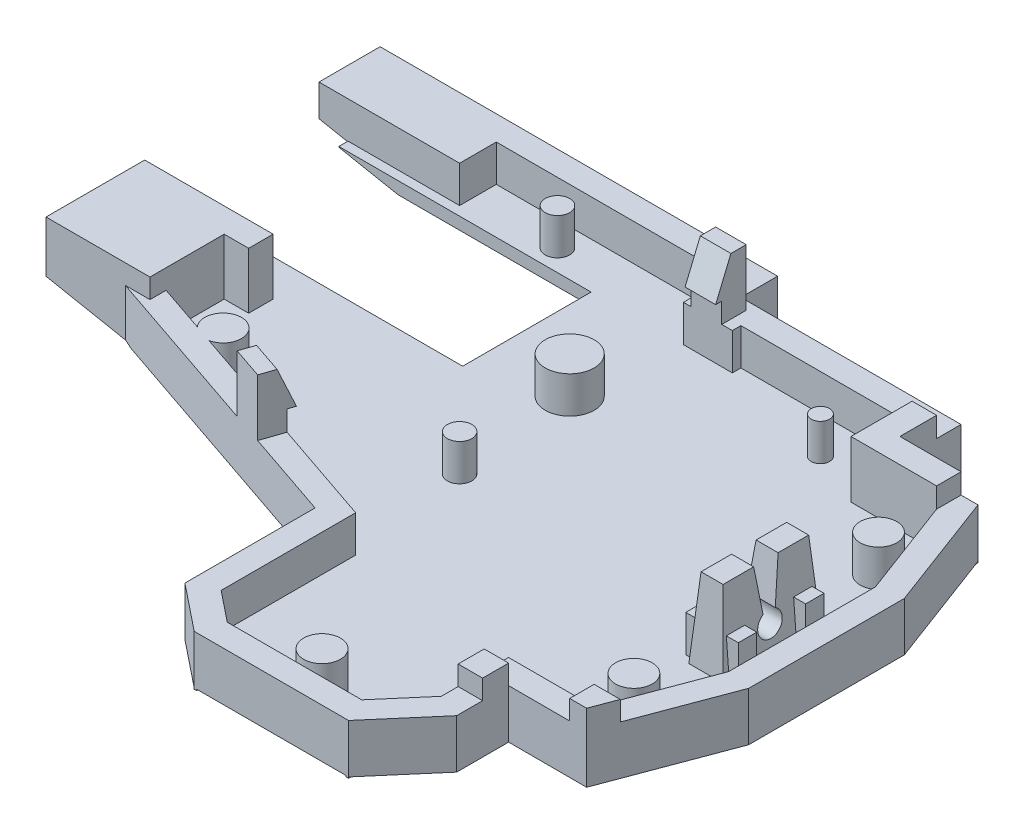
from build123d import *

# Parameters (mm, degrees)
SKETCH13_W           = 50
SKETCH13_H           = 45
BOSS_EXTRUDE4_DEPTH  = 1.6
SKETCH14_W           = 10
SKETCH14_H           = 8
CUT_EXTRUDE6_DEPTH   = 2.6
SKETCH15_W           = 18
SKETCH15_H           = 3
CUT_EXTRUDE7_DEPTH   = 2.6
SKETCH16_W           = 4
SKETCH16_H           = 0.7
CUT_EXTRUDE8_DEPTH   = 2.6
CUT_EXTRUDE9_DEPTH   = 2.6
SKETCH18_W           = 21.109590793
SKETCH18_H           = 22.840524871
CUT_EXTRUDE10_DEPTH  = 2.6
CUT_EXTRUDE11_DEPTH  = 2.6
SKETCH22_W           = 2
SKETCH22_H           = 3
CUT_EXTRUDE12_DEPTH  = 2.6
CUT_EXTRUDE13_DEPTH  = 2.6
CUT_EXTRUDE14_DEPTH  = 2.6
SKETCH25_W           = 2.8
SKETCH25_H           = 8
CUT_EXTRUDE15_DEPTH  = 2.6
BOSS_EXTRUDE6_DEPTH  = 6
SKETCH30_W           = 2.8
SKETCH30_H           = 8
BOSS_EXTRUDE7_DEPTH  = 3.5
CUT_EXTRUDE16_DEPTH  = 4.6
SKETCH32_W           = 2.8
SKETCH32_H           = 8
BOSS_EXTRUDE8_DEPTH  = 4.6
CUT_EXTRUDE18_DEPTH  = 4.6
SKETCH37_R           = 1
CUT_EXTRUDE19_DEPTH  = 4.6
CUT_EXTRUDE20_DEPTH  = 4.6
CUT_EXTRUDE21_START  = 6
CUT_EXTRUDE21_DEPTH  = 20.059798
BOSS_EXTRUDE9_DEPTH  = 4.6
SKETCH44_W           = 4.3
SKETCH44_H           = 1.5
BOSS_EXTRUDE11_DEPTH = 3
SKETCH45_R           = 1.5
SKETCH45_R_2         = 1
SKETCH45_R_3         = 1.999622229
SKETCH45_R_4         = 1.503341979
SKETCH45_R_5         = 0.75
BOSS_EXTRUDE12_DEPTH = 3
SKETCH46_W           = 2.5
SKETCH46_H           = 2
SKETCH46_W_2         = 2
BOSS_EXTRUDE13_DEPTH = 1.65
SKETCH47_W           = 3
SKETCH47_H           = 3
BOSS_EXTRUDE14_DEPTH = 3
SKETCH48_W           = 2
SKETCH48_H           = 16.336241737
CUT_EXTRUDE22_DEPTH  = 3
SKETCH49_W           = 21.336241737
SKETCH49_H           = 3
BOSS_EXTRUDE15_DEPTH = 13
SKETCH50_W           = 67
SKETCH50_H           = 49
BOSS_EXTRUDE16_DEPTH = 3
SKETCH51_W           = 5
SKETCH51_H           = 11
BOSS_EXTRUDE17_DEPTH = 15.6
CUT_EXTRUDE23_DEPTH  = 1.65
SKETCH53_W           = 2
SKETCH53_H           = 2.129349353
BOSS_EXTRUDE18_DEPTH = 1.6
SKETCH55_W           = 2.5
SKETCH55_H           = 2.5
BOSS_EXTRUDE20_DEPTH = 3
CUT_EXTRUDE24_DEPTH  = 3
SKETCH58_W           = 20
SKETCH58_H           = 10.5
SKETCH58_W_2         = 2
SKETCH58_H_2         = 2
CUT_EXTRUDE29_DEPTH  = 1
BOSS_EXTRUDE21_DEPTH = 3
BOSS_EXTRUDE22_REACH = 41.731
SKETCH61_W           = 2.5
SKETCH61_H           = 1.65
CUT_EXTRUDE30_DEPTH  = 3
CUT_EXTRUDE31_REACH  = 43.731
SKETCH64_W           = 2.551500858
SKETCH64_H           = 4.310788114
CUT_EXTRUDE32_DEPTH  = 4.65
SKETCH65_W           = 2
SKETCH65_H           = 2
BOSS_EXTRUDE23_DEPTH = 4
SKETCH66_W           = 2
SKETCH66_H           = 2
BOSS_EXTRUDE24_DEPTH = 1.6
SKETCH67_W           = 2.5
SKETCH67_H           = 2
BOSS_EXTRUDE25_DEPTH = 3
CUT_EXTRUDE33_DEPTH  = 3
BOSS_EXTRUDE26_DEPTH = 1.65
SKETCH70_W           = 5.055009343
SKETCH70_H           = 5.560438358
CUT_EXTRUDE34_DEPTH  = 3
BOSS_EXTRUDE27_DEPTH = 3
CUT_EXTRUDE35_DEPTH  = 3
BOSS_EXTRUDE28_REACH = 39.863
CUT_EXTRUDE36_DEPTH  = 3
FILLET8_R            = 1
SKETCH76_W           = 7
SKETCH76_H           = 14.5
BOSS_EXTRUDE29_DEPTH = 14.5
BOSS_EXTRUDE30_DEPTH = 2
CUT_EXTRUDE37_DEPTH  = 2
BOSS_EXTRUDE31_DEPTH = 2.684479
SKETCH85_W           = 30.566158209
SKETCH85_H           = 1.725230041
BOSS_EXTRUDE33_DEPTH = 3
BOSS_EXTRUDE34_DEPTH = 3
BOSS_EXTRUDE35_DEPTH = 3
SKETCH88_W           = 27.09375
SKETCH88_H           = 14.5
BOSS_EXTRUDE36_DEPTH = 1.6
SKETCH90_W           = 7
SKETCH90_H           = 14.5
BOSS_EXTRUDE37_DEPTH = 1.6
SKETCH93_W           = 5
SKETCH93_H           = 11
BOSS_EXTRUDE38_DEPTH = 0.5
SKETCH94_W           = 8.605758832
SKETCH94_H           = 2
BOSS_EXTRUDE39_DEPTH = 15.6
SKETCH96_W           = 8.605758832
SKETCH96_H           = 2
BOSS_EXTRUDE40_DEPTH = 0.5
SKETCH97_W           = 2
SKETCH97_H           = 49
BOSS_EXTRUDE41_DEPTH = 19.1
SKETCH98_W           = 69
SKETCH98_H           = 2
BOSS_EXTRUDE42_DEPTH = 19.1
SKETCH99_W           = 2
SKETCH99_H           = 3
BOSS_EXTRUDE43_DEPTH = 2.087376
SKETCH100_W          = 2
SKETCH100_H          = 51
BOSS_EXTRUDE45_DEPTH = 19.1
SKETCH101_W          = 71
SKETCH101_H          = 2
BOSS_EXTRUDE46_DEPTH = 19.1
BOSS_EXTRUDE47_DEPTH = 16.1
BOSS_EXTRUDE48_DEPTH = 16.1
FILLET9_R            = 2
SKETCH105_OUTSIDE_W  = 91.128
SKETCH105_OUTSIDE_H  = 73.128
CUT_EXTRUDE38_DEPTH  = 3
SKETCH106_W          = 77.0560479
SKETCH106_H          = 58.523580684
CUT_EXTRUDE39_DEPTH  = 20.1
SKETCH107_W          = 13.37564089
SKETCH107_H          = 6.179627402
CUT_EXTRUDE40_DEPTH  = 11.5
CUT_EXTRUDE41_DEPTH  = 4
SKETCH114_W          = 66.336817547
SKETCH114_H          = 51.668552302
CUT_EXTRUDE42_DEPTH  = 2
BOSS_EXTRUDE49_DEPTH = 6.5
SKETCH116_W          = 0.628599621
SKETCH116_H          = 10.5
CUT_EXTRUDE43_DEPTH  = 6.5
SKETCH117_W          = 8.5
SKETCH117_H          = 8.070282703
BOSS_EXTRUDE50_DEPTH = 1.6
SKETCH121_W          = 41.947556189
SKETCH121_H          = 104.538908281
CUT_EXTRUDE44_DEPTH  = 2.374278057
SKETCH122_W          = 0.2
SKETCH122_H          = 0.2
BOSS_EXTRUDE51_DEPTH = 0.1
SKETCH123_W          = 0.2
SKETCH123_H          = 0.2
BOSS_EXTRUDE52_DEPTH = 0.1
SKETCH124_W          = 0.2
SKETCH124_H          = 0.2
BOSS_EXTRUDE53_DEPTH = 0.1
SKETCH125_W          = 0.2
SKETCH125_H          = 0.2
BOSS_EXTRUDE54_DEPTH = 0.1


with BuildPart() as part:
    # Sketch13 → Boss-Extrude4 (new body)
    with BuildSketch(Plane(origin=(0, 0, 0), x_dir=(1, 0, 0), z_dir=(0, 1, 0))):
        with Locations((25, -22.5)):
            Rectangle(SKETCH13_W, SKETCH13_H)
    extrude(amount=BOSS_EXTRUDE4_DEPTH)

    # Sketch14 → Cut-Extrude6 (cut, through all)
    with BuildSketch(Plane(origin=(0, 1.6, 0), x_dir=(1, 0, 0), z_dir=(0, 1, 0))):
        with Locations((45, -4)):
            Rectangle(SKETCH14_W, SKETCH14_H)
    extrude(amount=-CUT_EXTRUDE6_DEPTH, mode=Mode.SUBTRACT)

    # Sketch15 → Cut-Extrude7 (cut, through all)
    with BuildSketch(Plane(origin=(0, 1.6, 0), x_dir=(1, 0, 0), z_dir=(0, 1, 0))):
        with Locations((31, -1.5)):
            Rectangle(SKETCH15_W, SKETCH15_H)
    extrude(amount=-CUT_EXTRUDE7_DEPTH, mode=Mode.SUBTRACT)

    # Sketch16 → Cut-Extrude8 (cut, through all)
    with BuildSketch(Plane(origin=(0, 1.6, 0), x_dir=(1, 0, 0), z_dir=(0, 1, 0))):
        with Locations((24, -3.35)):
            Rectangle(SKETCH16_W, SKETCH16_H)
    extrude(amount=-CUT_EXTRUDE8_DEPTH, mode=Mode.SUBTRACT)

    # Sketch17 → Cut-Extrude9 (cut, through all)
    with BuildSketch(Plane(origin=(0, 1.6, 0), x_dir=(1, 0, 0), z_dir=(0, 1, 0))):
        Polygon((47, -8), (50, -16), (65.881056194, -16), (65.881056194, 17.957346821), (47, 17.957346821), align=None)
    extrude(amount=-CUT_EXTRUDE9_DEPTH, mode=Mode.SUBTRACT)

    # Sketch18 → Cut-Extrude10 (cut, through all)
    with BuildSketch(Plane(origin=(0, 1.6, 0), x_dir=(1, 0, 0), z_dir=(0, 1, 0))):
        with Locations((50.554795396, -47.420262436)):
            Rectangle(SKETCH18_W, SKETCH18_H)
    extrude(amount=-CUT_EXTRUDE10_DEPTH, mode=Mode.SUBTRACT)

    # Sketch21 → Cut-Extrude11 (cut, through all)
    with BuildSketch(Plane(origin=(0, 1.6, 0), x_dir=(1, 0, 0), z_dir=(0, 1, 0))):
        Polygon((50, -28), (47, -36), (47, -49.297594069), (75.196774358, -49.297594069), (75.196774358, -28), align=None)
    extrude(amount=-CUT_EXTRUDE11_DEPTH, mode=Mode.SUBTRACT)

    # Sketch22 → Cut-Extrude12 (cut, through all)
    with BuildSketch(Plane(origin=(0, 1.6, 0), x_dir=(1, 0, 0), z_dir=(0, 1, 0))):
        with Locations((1, -20.836241737)):
            Rectangle(SKETCH22_W, SKETCH22_H)
    extrude(amount=-CUT_EXTRUDE12_DEPTH, mode=Mode.SUBTRACT)

    # Sketch23 → Cut-Extrude13 (cut, through all)
    with BuildSketch(Plane(origin=(0, 1.6, 0), x_dir=(1, 0, 0), z_dir=(0, 1, 0))):
        Polygon((23.5, -45), (23.5, -32), (0, -26.336241737), (-30.2261683, -26.336241737), (-30.2261683, -63.188280898), (23.5, -63.188280898), align=None)
    extrude(amount=-CUT_EXTRUDE13_DEPTH, mode=Mode.SUBTRACT)

    # Sketch24 → Cut-Extrude14 (cut, through all)
    with BuildSketch(Plane(origin=(0, 1.6, 0), x_dir=(1, 0, 0), z_dir=(0, 1, 0))):
        Polygon((23.5, -43), (7.491129632, -43), (7.491129632, -69.550234766), (44.754002286, -69.550234766), (44.754002286, -41.5), (40, -41.5), (37, -45), (26, -45), align=None)
    extrude(amount=-CUT_EXTRUDE14_DEPTH, mode=Mode.SUBTRACT)

    # Sketch25 → Cut-Extrude15 (cut, through all)
    with BuildSketch(Plane(origin=(0, 1.6, 0), x_dir=(1, 0, 0), z_dir=(0, 1, 0))):
        with Locations((46.200745069, -22.059797812)):
            Rectangle(SKETCH25_W, SKETCH25_H)
    extrude(amount=-CUT_EXTRUDE15_DEPTH, mode=Mode.SUBTRACT)

    # Sketch28 → Boss-Extrude6 (add)
    with BuildSketch(Plane.XZ):
        Polygon((42, 38), (42, 42.239848152), (37.919869845, 47), (25.298437881, 47), (21.5, 43.961249695), (21.5, 33.575244456), (-2, 27.911486193), (-2, -2), (24, -2), (24, 1), (42, 1), (42, 6), (48.386000936, 6), (52, 15.637330836), (52, 28.362669164), (48.386000936, 38), align=None)
    extrude(amount=BOSS_EXTRUDE6_DEPTH)

    # Sketch30 → Boss-Extrude7 (add)
    with BuildSketch(Plane(origin=(0, 0, 0), x_dir=(1, 0, 0), z_dir=(0, 1, 0))):
        with Locations((46.200745069, -22.059797812)):
            Rectangle(SKETCH30_W, SKETCH30_H)
    extrude(amount=BOSS_EXTRUDE7_DEPTH)

    # Sketch31 → Cut-Extrude16 (cut)
    with BuildSketch(Plane(origin=(0, 1.6, 0), x_dir=(1, 0, 0), z_dir=(0, 1, 0))):
        Polygon((37, -45), (40, -41.5), (40, -36), (47, -36), (50, -28), (50, -16), (47, -8), (40, -8), (40, -3), (26, -3), (26, -3.7), (22, -3.7), (22, 0), (0, 0), (0, -19.336241737), (2, -19.336241737), (2, -22.336241737), (0, -22.336241737), (0, -26.336241737), (23.5, -32), (23.5, -43), (26, -45), align=None)
    extrude(amount=-CUT_EXTRUDE16_DEPTH, mode=Mode.SUBTRACT)

    # Sketch32 → Boss-Extrude8 (add)
    with BuildSketch(Plane.XZ.offset(-1.6)):
        with Locations((46.200745069, 22.059797812)):
            Rectangle(SKETCH32_W, SKETCH32_H)
    extrude(amount=BOSS_EXTRUDE8_DEPTH)

    # Sketch35 → Cut-Extrude18 (cut)
    with BuildSketch(Plane(origin=(47.600745069, 0, 0), x_dir=(0, 0, -1), z_dir=(1, 0, 0))):
        Polygon((-22.059797812, 0), (-21.559797812, 0), (-21.059797812, 3.5), (-21.297672794, 5.165124873), (-23.257672794, 4.885124873), (-23.059797812, 3.5), (-22.559797812, 0), align=None)
    extrude(amount=-CUT_EXTRUDE18_DEPTH, mode=Mode.SUBTRACT)

    # Sketch37 → Cut-Extrude19 (cut)
    with BuildSketch(Plane(origin=(47.600745069, 0, 0), x_dir=(0, 0, -1), z_dir=(1, 0, 0))):
        with Locations((-22.059797812, -0.866025404)):
            Circle(SKETCH37_R)
    extrude(amount=-CUT_EXTRUDE19_DEPTH, mode=Mode.SUBTRACT)

    # Sketch39 → Cut-Extrude20 (cut)
    with BuildSketch(Plane.ZY.offset(-44.800745069)):
        Polygon((25.559797812, 3.5), (26.059797812, -3), (27.906381513, -2.8579551), (27.406381513, 3.6420449), align=None)
        Polygon((18.559797812, 3.5), (18.059797812, -3), (15.957253652, -2.838265834), (16.455739093, 3.6420449), align=None)
    extrude(amount=-CUT_EXTRUDE20_DEPTH, mode=Mode.SUBTRACT)

    # Sketch41 → Cut-Extrude21 (cut)
    with BuildSketch(Plane.XY.offset(CUT_EXTRUDE21_START)):
        Polygon((45.300745069, 3.5), (44.800745069, -3), (43.414957387, -2.893400947), (43.940591177, 3.939838325), align=None)
        Polygon((47.100745069, 3.5), (47.600745069, -3), (49.658968536, -2.841675118), (49.137313656, 3.939838325), align=None)
    extrude(amount=CUT_EXTRUDE21_DEPTH, mode=Mode.SUBTRACT)

    # Sketch43 → Boss-Extrude9 (add)
    with BuildSketch(Plane(origin=(0, 0, 0), x_dir=(1, 0, 0), z_dir=(0, 1, 0))):
        Polygon((47, -8), (50, -16), (51.170411472, -13.425094762), (48.386000936, -6), (42.818763345, -6), (42.818763345, -8), align=None)
    extrude(amount=-BOSS_EXTRUDE9_DEPTH)

    # Sketch44 → Boss-Extrude11 (add)
    with BuildSketch(Plane(origin=(0, -3, 0), x_dir=(1, 0, 0), z_dir=(0, 1, 0))):
        with Locations((46.200745069, -19.309797812)):
            Rectangle(SKETCH44_W, SKETCH44_H)
        with Locations((46.200745069, -24.809797812)):
            Rectangle(SKETCH44_W, SKETCH44_H)
    extrude(amount=BOSS_EXTRUDE11_DEPTH)

    # Sketch45 → Boss-Extrude12 (add)
    with BuildSketch(Plane(origin=(0, -3, 0), x_dir=(1, 0, 0), z_dir=(0, 1, 0))):
        with Locations((46.25, -12)):
            Circle(SKETCH45_R)
        with Locations((46.25, -32)):
            Circle(SKETCH45_R)
        with Locations((22, -22)):
            Circle(SKETCH45_R_2)
        with Locations((21, -12)):
            Circle(SKETCH45_R_3)
        with Locations((31.75, -43)):
            Circle(SKETCH45_R_4)
        with Locations((35.5, -6)):
            Circle(SKETCH45_R_5)
        with Locations((10, -2)):
            Circle(SKETCH45_R_2)
        with Locations((5, -24.336241737)):
            Circle(SKETCH45_R)
    extrude(amount=BOSS_EXTRUDE12_DEPTH)

    # Sketch46 → Boss-Extrude13 (add)
    with BuildSketch(Plane(origin=(0, 0, 0), x_dir=(1, 0, 0), z_dir=(0, 1, 0))):
        Polygon((14.137316506, -29.743490383), (16.567726059, -30.329245795), (16.099121729, -32.273573438), (13.668712176, -31.687818026), align=None)
        with Locations((23.883625006, -2.7)):
            Rectangle(SKETCH46_W, SKETCH46_H)
        with Locations((1, -20.932723283)):
            Rectangle(SKETCH46_W_2, SKETCH46_H)
        Polygon((47, -36), (48.872658355, -36.702246883), (49.750466959, -34.361423939), (47.877808604, -33.659177056), align=None)
        Polygon((40, -3), (40, -8), (47, -8), (47, -6), (42, -6), (42, -3), align=None)
    extrude(amount=BOSS_EXTRUDE13_DEPTH)

    # Sketch47 → Boss-Extrude14 (add)
    with BuildSketch(Plane(origin=(0, 0, 0), x_dir=(1, 0, 0), z_dir=(0, 1, 0))):
        with Locations((1.5, -1.5)):
            Rectangle(SKETCH47_W, SKETCH47_H)
    extrude(amount=-BOSS_EXTRUDE14_DEPTH)

    # Sketch48 → Cut-Extrude22 (cut)
    with BuildSketch(Plane(origin=(0, 0, 0), x_dir=(1, 0, 0), z_dir=(0, 1, 0))):
        with Locations((-1, -11.168120869)):
            Rectangle(SKETCH48_W, SKETCH48_H)
    extrude(amount=-CUT_EXTRUDE22_DEPTH, mode=Mode.SUBTRACT)

    # Sketch49 → Boss-Extrude15 (add)
    with BuildSketch(Plane.ZY.offset(2)):
        with Locations((8.668120869, -4.5)):
            Rectangle(SKETCH49_W, SKETCH49_H)
    extrude(amount=BOSS_EXTRUDE15_DEPTH)

    # Sketch50 → Boss-Extrude16 (add)
    with BuildSketch(Plane.XZ.offset(6)):
        with Locations((18.5, 22.5)):
            Rectangle(SKETCH50_W, SKETCH50_H)
    extrude(amount=-BOSS_EXTRUDE16_DEPTH)

    # Sketch51 → Boss-Extrude17 (add)
    with BuildSketch(Plane(origin=(0, -3, 0), x_dir=(1, 0, 0), z_dir=(0, 1, 0))):
        with Locations((49.5, -41.5)):
            Rectangle(SKETCH51_W, SKETCH51_H)
    extrude(amount=BOSS_EXTRUDE17_DEPTH)

    # Sketch52 → Cut-Extrude23 (cut)
    with BuildSketch(Plane(origin=(0, 1.65, 0), x_dir=(1, 0, 0), z_dir=(0, 1, 0))):
        Polygon((47.877808604, -33.659177056), (47, -36), (49.136000936, -36), (49.750466959, -34.361423939), align=None)
    extrude(amount=-CUT_EXTRUDE23_DEPTH, mode=Mode.SUBTRACT)

    # Sketch53 → Boss-Extrude18 (add)
    with BuildSketch(Plane(origin=(0, 0, 0), x_dir=(1, 0, 0), z_dir=(0, 1, 0))):
        with Locations((41, -39.055249399)):
            Rectangle(SKETCH53_W, SKETCH53_H)
    extrude(amount=BOSS_EXTRUDE18_DEPTH)

    # Sketch55 → Boss-Extrude20 (add)
    with BuildSketch(Plane(origin=(0, 1.65, 0), x_dir=(1, 0, 0), z_dir=(0, 1, 0))):
        with Locations((23.883625006, -2.95)):
            Rectangle(SKETCH55_W, SKETCH55_H)
    extrude(amount=BOSS_EXTRUDE20_DEPTH)

    # Sketch56 → Cut-Extrude24 (cut)
    with BuildSketch(Plane(origin=(25.133625006, 0, 0), x_dir=(0, 0, -1), z_dir=(1, 0, 0))):
        Polygon((-4.2, 1.65), (-2.95, 4.65), (-2.95, 7.68728323), (-6.59715338, 7.68728323), (-6.59715338, 1.641289328), align=None)
    extrude(amount=-CUT_EXTRUDE24_DEPTH, mode=Mode.SUBTRACT)

    # Sketch58 → Cut-Extrude29 (cut)
    with BuildSketch(Plane(origin=(0, -3, 0), x_dir=(1, 0, 0), z_dir=(0, 1, 0))):
        with Locations((4.5, -9)):
            Rectangle(SKETCH58_W, SKETCH58_H)
        with Locations((1, -18.248866233)):
            Rectangle(SKETCH58_W_2, SKETCH58_H_2)
    extrude(amount=-CUT_EXTRUDE29_DEPTH, mode=Mode.SUBTRACT)

    # Sketch60 → Boss-Extrude21 (add)
    with BuildSketch(Plane(origin=(0, -3, 0), x_dir=(1, 0, 0), z_dir=(0, 1, 0))):
        Polygon((0, -24), (23.5, -32), (0, -26.336241737), align=None)
    extrude(amount=BOSS_EXTRUDE21_DEPTH)

    # Boss-Extrude22: up to this face of the body (flat: up to its plane)
    boss_extrude22_end = Plane(part.part.faces().sort_by_distance((14.401539714, -1.5, 28.902651818))[0])
    # Sketch61 → Boss-Extrude22 (add, up to the picked face)
    with BuildSketch(Plane(origin=(-5.998871461, 0, 24.890447788), x_dir=(-0.972163821, 0, -0.234302165), z_dir=(0.234302165, 0, -0.972163821)), mode=Mode.PRIVATE) as boss_extrude22_sk1:
        with Locations((-21.962751827, 0.825)):
            Rectangle(SKETCH61_W, SKETCH61_H)
    boss_extrude22_tool1 = split(extrude(boss_extrude22_sk1.sketch, amount=BOSS_EXTRUDE22_REACH, mode=Mode.PRIVATE), bisect_by=boss_extrude22_end, keep=Keep.BOTH, mode=Mode.PRIVATE)
    add(boss_extrude22_tool1.solids().sort_by_distance((15.352521, 0.825, 30.036368))[0])

    # Sketch62 → Cut-Extrude30 (cut)
    with BuildSketch(Plane(origin=(0, 0, 0), x_dir=(1, 0, 0), z_dir=(0, 1, 0))):
        Polygon((0, -26), (-0.545193502, -28.262110548), (-9.931116312, -26), (-9.25988925, -22.847697277), align=None)
    extrude(amount=-CUT_EXTRUDE30_DEPTH, mode=Mode.SUBTRACT)

    # Cut-Extrude31: up to this face of the body (flat: up to its plane)
    cut_extrude31_end = Plane(part.part.faces().sort_by_distance((-1, -1.5, 25.659574468))[0])
    # Sketch63 → Cut-Extrude31 (cut, up to the picked face)
    with BuildSketch(Plane(origin=(-6.46747579, 0, 26.834775431), x_dir=(0.972163821, 0, 0.234302165), z_dir=(-0.234302165, 0, 0.972163821)), mode=Mode.PRIVATE) as cut_extrude31_sk1:
        Polygon((20.712751827, 0), (6.091856288, 0), (6.091856288, -3), (28.768274623, -3), (28.768274623, 0), (23.212751827, 0), (23.212751827, 1.65), (20.712751827, 1.65), align=None)
    cut_extrude31_tool1 = split(extrude(cut_extrude31_sk1.sketch, amount=-CUT_EXTRUDE31_REACH, mode=Mode.PRIVATE), bisect_by=cut_extrude31_end, keep=Keep.BOTH, mode=Mode.PRIVATE)
    add(cut_extrude31_tool1.solids().sort_by_distance((10.72932, -1.367082, 30.979392))[0], mode=Mode.SUBTRACT)

    # Sketch64 → Cut-Extrude32 (cut)
    with BuildSketch(Plane(origin=(0, 1.65, 0), x_dir=(1, 0, 0), z_dir=(0, 1, 0))):
        with Locations((1.275750429, -20.806985271)):
            Rectangle(SKETCH64_W, SKETCH64_H)
    extrude(amount=-CUT_EXTRUDE32_DEPTH, mode=Mode.SUBTRACT)

    # Sketch65 → Boss-Extrude23 (add)
    with BuildSketch(Plane(origin=(0, -4, 0), x_dir=(1, 0, 0), z_dir=(0, 1, 0))):
        with Locations((1, -18.248866233)):
            Rectangle(SKETCH65_W, SKETCH65_H)
    extrude(amount=BOSS_EXTRUDE23_DEPTH)

    # Sketch66 → Boss-Extrude24 (add)
    with BuildSketch(Plane(origin=(0, 0, 0), x_dir=(1, 0, 0), z_dir=(0, 1, 0))):
        with Locations((1, -18.248866233)):
            Rectangle(SKETCH66_W, SKETCH66_H)
    extrude(amount=BOSS_EXTRUDE24_DEPTH)

    # Sketch67 → Boss-Extrude25 (add)
    with BuildSketch(Plane(origin=(0, 1.6, 0), x_dir=(1, 0, 0), z_dir=(0, 1, 0))):
        with Locations((1.25, -18.248866233)):
            Rectangle(SKETCH67_W, SKETCH67_H)
    extrude(amount=BOSS_EXTRUDE25_DEPTH)

    # Sketch68 → Cut-Extrude33 (cut)
    with BuildSketch(Plane(origin=(0, 0, 17.248866233), x_dir=(-1, 0, 0), z_dir=(0, 0, -1))):
        Polygon((-2.5, 1.6), (-1.25, 4.6), (-1.25, 6.77486743), (-4.497451498, 6.77486743), (-4.497451498, 1.567063174), align=None)
    extrude(amount=-CUT_EXTRUDE33_DEPTH, mode=Mode.SUBTRACT)

    # Sketch69 → Boss-Extrude26 (add)
    with BuildSketch(Plane(origin=(0, 1.65, 0), x_dir=(1, 0, 0), z_dir=(0, 1, 0))):
        Polygon((14.344636536, -28.883280523), (16.885898362, -29.748390932), (16.275756374, -31.540683021), (13.734494548, -30.675572612), align=None)
    extrude(amount=-BOSS_EXTRUDE26_DEPTH)

    # Sketch70 → Cut-Extrude34 (cut)
    with BuildSketch(Plane.XY.offset(19.248866233)):
        with Locations((-0.027504672, 4.380219179)):
            Rectangle(SKETCH70_W, SKETCH70_H)
    extrude(amount=-CUT_EXTRUDE34_DEPTH, mode=Mode.SUBTRACT)

    # Sketch71 → Boss-Extrude27 (add)
    with BuildSketch(Plane(origin=(0, 1.65, 0), x_dir=(1, 0, 0), z_dir=(0, 1, 0))):
        Polygon((16.275756374, -31.540683021), (17.081415869, -29.174058256), (14.559846057, -28.298525857), (13.734494548, -30.675572612), align=None)
    extrude(amount=BOSS_EXTRUDE27_DEPTH)

    # Sketch72 → Cut-Extrude35 (cut)
    with BuildSketch(Plane(origin=(24.207602216, 0, 8.240885861), x_dir=(0.322263798, 0, -0.946649906), z_dir=(0.946649906, 0, 0.322263798))):
        Polygon((-22.112897557, 1.65), (-23.362897557, 4.65), (-23.362897557, 7.694800469), (-20.734818485, 7.694800469), (-20.734818485, 1.65), align=None)
    extrude(amount=-CUT_EXTRUDE35_DEPTH, mode=Mode.SUBTRACT)

    # Boss-Extrude28: up to this face of the body (flat: up to its plane)
    boss_extrude28_end = Plane(part.part.faces().sort_by_distance((14.039565542, 0.825, 29.779426567))[0])
    # Sketch73 → Boss-Extrude28 (add, up to the picked face)
    with BuildSketch(Plane(origin=(21.761963317, 0, 7.556127878), x_dir=(-0.328007452, 0, 0.944675136), z_dir=(-0.944675136, 0, -0.328007452)), mode=Mode.PRIVATE) as boss_extrude28_sk1:
        Polygon((24.473434161, 4.65), (23.223411105, 4.65), (21.973388049, 1.65), (22.580099427, 1.65), (24.473434161, 1.65), align=None)
    boss_extrude28_tool1 = split(extrude(boss_extrude28_sk1.sketch, amount=BOSS_EXTRUDE28_REACH, mode=Mode.PRIVATE), bisect_by=boss_extrude28_end, keep=Keep.BOTH, mode=Mode.PRIVATE)
    add(boss_extrude28_tool1.solids().sort_by_distance((14.053397, 2.983333, 29.757122))[0])

    # Sketch74 → Cut-Extrude36 (cut)
    with BuildSketch(Plane(origin=(0, -4, 0), x_dir=(1, 0, 0), z_dir=(0, 1, 0))):
        with BuildLine():
            Line((6.419171569, -6.169171569), (2.580828431, -6.169171569))
            ThreePointArc((2.580828431, -6.169171569), (-0.25, -9), (2.580828431, -11.830828431))
            Line((2.580828431, -11.830828431), (6.419171569, -11.830828431))
            ThreePointArc((6.419171569, -11.830828431), (9.25, -9), (6.419171569, -6.169171569))
        make_face()
    extrude(amount=-CUT_EXTRUDE36_DEPTH, mode=Mode.SUBTRACT)

    # Fillet8
    fillet8_edges = [part.edges().sort_by_distance(p)[0] for p in [
        (-0.25, -6, 9),
        (4.5, -6, 6.169171569),
        (9.25, -6, 9),
        (4.5, -6, 11.830828431),
    ]]
    fillet(fillet8_edges, radius=FILLET8_R)

    # Sketch76 → Boss-Extrude29 (add)
    with BuildSketch(Plane(origin=(0, -3, 0), x_dir=(1, 0, 0), z_dir=(0, 1, 0))):
        with Locations((-11.5, -39.75)):
            Rectangle(SKETCH76_W, SKETCH76_H)
    extrude(amount=BOSS_EXTRUDE29_DEPTH)

    # Sketch79 → Boss-Extrude30 (add)
    with BuildSketch(Plane(origin=(21.66634039, 0, 7.375775452), x_dir=(-0.322263798, 0, 0.946649906), z_dir=(-0.946649906, 0, -0.322263798))):
        Polygon((22.719597745, 0), (24.612897557, 0), (24.612897557, 4.65), (23.362851444, 4.65), (22.112805332, 1.65), (22.719597745, 1.65), align=None)
    extrude(amount=BOSS_EXTRUDE30_DEPTH)

    # Sketch80 → Cut-Extrude37 (cut)
    with BuildSketch(Plane(origin=(24.207602216, 0, 8.240885861), x_dir=(0.322263798, 0, -0.946649906), z_dir=(0.946649906, 0, 0.322263798))):
        Polygon((-22.112897557, 1.65), (-23.362897557, 4.65), (-24.612897557, 4.65), (-24.612897557, 0), (-22.719597745, 0), (-22.719597745, 1.65), align=None)
    extrude(amount=-CUT_EXTRUDE37_DEPTH, mode=Mode.SUBTRACT)

    # Sketch83 → Boss-Extrude31 (add)
    with BuildSketch(Plane(origin=(19.773040578, 0, 6.731247856), x_dir=(-0.322263798, 0, 0.946649906), z_dir=(-0.946649906, 0, -0.322263798))):
        Polygon((22.719597745, 1.65), (22.719597745, 0), (24.612897557, 0), (24.612897557, 4.65), (23.362851444, 4.65), (22.112805332, 1.65), align=None)
    extrude(amount=-BOSS_EXTRUDE31_DEPTH)

    # Sketch85 → Boss-Extrude33 (add)
    with BuildSketch(Plane(origin=(0, -3, 0), x_dir=(1, 0, 0), z_dir=(0, 1, 0))):
        with Locations((7.283079105, -33.362615021)):
            Rectangle(SKETCH85_W, SKETCH85_H)
    extrude(amount=BOSS_EXTRUDE33_DEPTH)

    # Sketch86 → Boss-Extrude34 (add)
    with BuildSketch(Plane(origin=(0, -3, 0), x_dir=(1, 0, 0), z_dir=(0, 1, 0))):
        Polygon((21.5, -43.961249695), (21.5, -34.225230041), (-8, -34.225230041), (-8, -47), (25.298437881, -47), align=None)
    extrude(amount=BOSS_EXTRUDE34_DEPTH)

    # Sketch87 → Boss-Extrude35 (add)
    with BuildSketch(Plane(origin=(0, -3, 0), x_dir=(1, 0, 0), z_dir=(0, 1, 0))):
        Polygon((37.919869845, -47), (47, -47), (47, -38), (42, -38), (42, -42.239848152), align=None)
    extrude(amount=BOSS_EXTRUDE35_DEPTH)

    # Sketch88 → Boss-Extrude36 (add)
    with BuildSketch(Plane(origin=(0, 0, 0), x_dir=(1, 0, 0), z_dir=(0, 1, 0))):
        with Locations((5.546875, -39.75)):
            Rectangle(SKETCH88_W, SKETCH88_H)
    extrude(amount=BOSS_EXTRUDE36_DEPTH)

    # Sketch90 → Boss-Extrude37 (add)
    with BuildSketch(Plane(origin=(0, 11.5, 0), x_dir=(1, 0, 0), z_dir=(0, 1, 0))):
        with Locations((-11.5, -39.75)):
            Rectangle(SKETCH90_W, SKETCH90_H)
    extrude(amount=BOSS_EXTRUDE37_DEPTH)

    # Sketch93 → Boss-Extrude38 (add)
    with BuildSketch(Plane(origin=(0, 12.6, 0), x_dir=(1, 0, 0), z_dir=(0, 1, 0))):
        with Locations((49.5, -41.5)):
            Rectangle(SKETCH93_W, SKETCH93_H)
    extrude(amount=BOSS_EXTRUDE38_DEPTH)

    # Sketch94 → Boss-Extrude39 (add)
    with BuildSketch(Plane(origin=(0, -3, 0), x_dir=(1, 0, 0), z_dir=(0, 1, 0))):
        with Locations((5.421445221, -31.5)):
            Rectangle(SKETCH94_W, SKETCH94_H)
    extrude(amount=BOSS_EXTRUDE39_DEPTH)

    # Sketch96 → Boss-Extrude40 (add)
    with BuildSketch(Plane(origin=(0, 12.6, 0), x_dir=(1, 0, 0), z_dir=(0, 1, 0))):
        with Locations((5.421445221, -31.5)):
            Rectangle(SKETCH96_W, SKETCH96_H)
    extrude(amount=BOSS_EXTRUDE40_DEPTH)

    # Sketch97 → Boss-Extrude41 (add)
    with BuildSketch(Plane.XZ.offset(6)):
        with Locations((-16, 22.5)):
            Rectangle(SKETCH97_W, SKETCH97_H)
    extrude(amount=-BOSS_EXTRUDE41_DEPTH)

    # Sketch98 → Boss-Extrude42 (add)
    with BuildSketch(Plane.XZ.offset(6)):
        with Locations((17.5, 48)):
            Rectangle(SKETCH98_W, SKETCH98_H)
    extrude(amount=-BOSS_EXTRUDE42_DEPTH)

    # Sketch99 → Boss-Extrude43 (add)
    with BuildSketch(Plane(origin=(0, 0, 19.336241737), x_dir=(-1, 0, 0), z_dir=(0, 0, -1))):
        with Locations((1, -1.5)):
            Rectangle(SKETCH99_W, SKETCH99_H)
    extrude(amount=BOSS_EXTRUDE43_DEPTH)

    # Sketch100 → Boss-Extrude45 (add)
    with BuildSketch(Plane.XZ.offset(6)):
        with Locations((53, 23.5)):
            Rectangle(SKETCH100_W, SKETCH100_H)
    extrude(amount=-BOSS_EXTRUDE45_DEPTH)

    # Sketch101 → Boss-Extrude46 (add)
    with BuildSketch(Plane.XZ.offset(6)):
        with Locations((18.5, -3)):
            Rectangle(SKETCH101_W, SKETCH101_H)
    extrude(amount=-BOSS_EXTRUDE46_DEPTH)

    # Sketch102 → Boss-Extrude47 (add)
    with BuildSketch(Plane(origin=(0, -3, 0), x_dir=(1, 0, 0), z_dir=(0, 1, 0))):
        with BuildLine():
            Line((50, 2), (50, 2.836676417))
            Line((50, 2.836676417), (52.928518438, 2.836676417))
            Line((52.928518438, 2.836676417), (52.928518438, 0))
            Line((52.928518438, 0), (52, 0))
            ThreePointArc((52, 0), (51.414213562, 1.414213562), (50, 2))
        make_face()
    extrude(amount=BOSS_EXTRUDE47_DEPTH)

    # Sketch103 → Boss-Extrude48 (add)
    with BuildSketch(Plane(origin=(0, -3, 0), x_dir=(1, 0, 0), z_dir=(0, 1, 0))):
        with BuildLine():
            Line((-13, 2), (-13, 3.319267165))
            Line((-13, 3.319267165), (-16.315139414, 3.319267165))
            Line((-16.315139414, 3.319267165), (-16.315139414, 0))
            Line((-16.315139414, 0), (-15, 0))
            ThreePointArc((-15, 0), (-14.414213562, 1.414213562), (-13, 2))
        make_face()
    extrude(amount=BOSS_EXTRUDE48_DEPTH)

    # Fillet9
    fillet9_edges = [part.edges().sort_by_distance(p)[0] for p in [
        (-17, -6, 22.5),
        (18.5, -6, 49),
        (-17, 3.55, 49),
        (54, -6, 22.5),
        (54, 3.55, 49),
        (18.5, -6, -4),
        (-17, 3.55, -4),
        (54, 3.55, -4),
    ]]
    fillet(fillet9_edges, radius=FILLET9_R)

    # Sketch105 outside → Cut-Extrude38 (cut)
    with BuildSketch(Plane(origin=(0, 13.1, 0), x_dir=(1, 0, 0), z_dir=(0, 1, 0))):
        with Locations((18.5, -22.5)):
            Rectangle(SKETCH105_OUTSIDE_W, SKETCH105_OUTSIDE_H)
        with BuildLine():
            Line((-16, 2), (-16, -47))
            ThreePointArc((-16, -47), (-15.707106781, -47.707106781), (-15, -48))
            Line((-15, -48), (52, -48))
            ThreePointArc((52, -48), (52.707106781, -47.707106781), (53, -47))
            Line((53, -47), (53, 2))
            ThreePointArc((53, 2), (52.707106781, 2.707106781), (52, 3))
            Line((52, 3), (-15, 3))
            ThreePointArc((-15, 3), (-15.707106781, 2.707106781), (-16, 2))
        make_face(mode=Mode.SUBTRACT)
    extrude(amount=-CUT_EXTRUDE38_DEPTH, mode=Mode.SUBTRACT)

    # Sketch106 → Cut-Extrude39 (cut, through all)
    with BuildSketch(Plane.XZ.offset(6)):
        with Locations((17.692589571, 21.631481201)):
            Rectangle(SKETCH106_W, SKETCH106_H)
        Polygon((-2, -2), (24, -2), (24, 1), (42, 1), (42, 6), (48.386000936, 6), (52, 15.637330836), (52, 28.362669164), (49.136000936, 36), (48.386000936, 38), (42, 37.990574723), (42, 42.239848152), (37.919869845, 47), (25.298437881, 47), (21.5, 43.961249695), (21.5, 33.319148936), (-2, 25.319148936), (-2, 17.248866233), (-8.372079234, 17.248866233), (-8.372079234, 3), (-2, 3), align=None, mode=Mode.SUBTRACT)
    extrude(amount=-CUT_EXTRUDE39_DEPTH, mode=Mode.SUBTRACT)

    # Sketch107 → Cut-Extrude40 (cut)
    with BuildSketch(Plane(origin=(0, 13.1, 0), x_dir=(1, 0, 0), z_dir=(0, 1, 0))):
        with Locations((44.784273424, -38.274312053)):
            Rectangle(SKETCH107_W, SKETCH107_H)
    extrude(amount=-CUT_EXTRUDE40_DEPTH, mode=Mode.SUBTRACT)

    # Sketch113 → Cut-Extrude41 (cut, through all)
    with BuildSketch(Plane(origin=(0, -3, 0), x_dir=(1, 0, 0), z_dir=(0, 1, 0))):
        Polygon((-6.128599621, -3), (-6.128599621, -14.861393841), (-2, -14.861393841), (-2, -17.248866233), (-9.246534053, -26.452427809), (-13.814435406, -0.657200841), (-2.974123127, 6.68981616), (-3.537653946, 5.974095989), align=None)
    extrude(amount=-CUT_EXTRUDE41_DEPTH, mode=Mode.SUBTRACT)

    # Sketch114 → Cut-Extrude42 (cut)
    with BuildSketch(Plane.XZ.offset(6)):
        with Locations((24.645555619, 22.809022442)):
            Rectangle(SKETCH114_W, SKETCH114_H)
    extrude(amount=-CUT_EXTRUDE42_DEPTH, mode=Mode.SUBTRACT)

    # Sketch115 → Boss-Extrude49 (add)
    with BuildSketch(Plane.ZY.offset(2)):
        Polygon((14.861393841, -3), (14.861393841, -4), (25.319148936, -4), (25.319148936, 0), (17.248866233, 0), (17.248866233, -3), align=None)
        Polygon((-2, 0), (-2, -4), (3, -4), (3, -3), (3, 0), align=None)
    extrude(amount=BOSS_EXTRUDE49_DEPTH)

    # Sketch116 → Cut-Extrude43 (cut)
    with BuildSketch(Plane(origin=(0, -3, 0), x_dir=(1, 0, 0), z_dir=(0, 1, 0))):
        with Locations((-5.81429981, -9)):
            Rectangle(SKETCH116_W, SKETCH116_H)
    extrude(amount=-CUT_EXTRUDE43_DEPTH, mode=Mode.SUBTRACT)

    # Sketch117 → Boss-Extrude50 (add)
    with BuildSketch(Plane(origin=(0, 0, 0), x_dir=(1, 0, 0), z_dir=(0, 1, 0))):
        with Locations((-4.25, -21.284007585)):
            Rectangle(SKETCH117_W, SKETCH117_H)
    extrude(amount=BOSS_EXTRUDE50_DEPTH)

    # Sketch121 → Cut-Extrude44 (cut, through all)
    with BuildSketch(Plane(origin=(-0.79645719, -4.097417033, 0), x_dir=(0.981627183, -0.190808995, 0), z_dir=(0.190808995, 0.981627183, 0))):
        with Locations((-1.037587354, -26.258689617)):
            Rectangle(SKETCH121_W, SKETCH121_H)
    extrude(amount=-CUT_EXTRUDE44_DEPTH, mode=Mode.SUBTRACT)

    # Sketch122 → Boss-Extrude51 (add)
    with BuildSketch(Plane.XZ.offset(4)):
        with Locations((41.9, 1.1)):
            Rectangle(SKETCH122_W, SKETCH122_H)
    extrude(amount=BOSS_EXTRUDE51_DEPTH)

    # Sketch123 → Boss-Extrude52 (add)
    with BuildSketch(Plane.XZ.offset(4)):
        with Locations((48.286000936, 6.1)):
            Rectangle(SKETCH123_W, SKETCH123_H)
    extrude(amount=BOSS_EXTRUDE52_DEPTH)

    # Sketch124 → Boss-Extrude53 (add)
    with BuildSketch(Plane.XZ.offset(4)):
        with Locations((25.398437881, 46.9)):
            Rectangle(SKETCH124_W, SKETCH124_H)
    extrude(amount=BOSS_EXTRUDE53_DEPTH)

    # Sketch125 → Boss-Extrude54 (add)
    with BuildSketch(Plane.XZ.offset(4)):
        with Locations((37.819869845, 46.9)):
            Rectangle(SKETCH125_W, SKETCH125_H)
    extrude(amount=BOSS_EXTRUDE54_DEPTH)


solid = part.part
